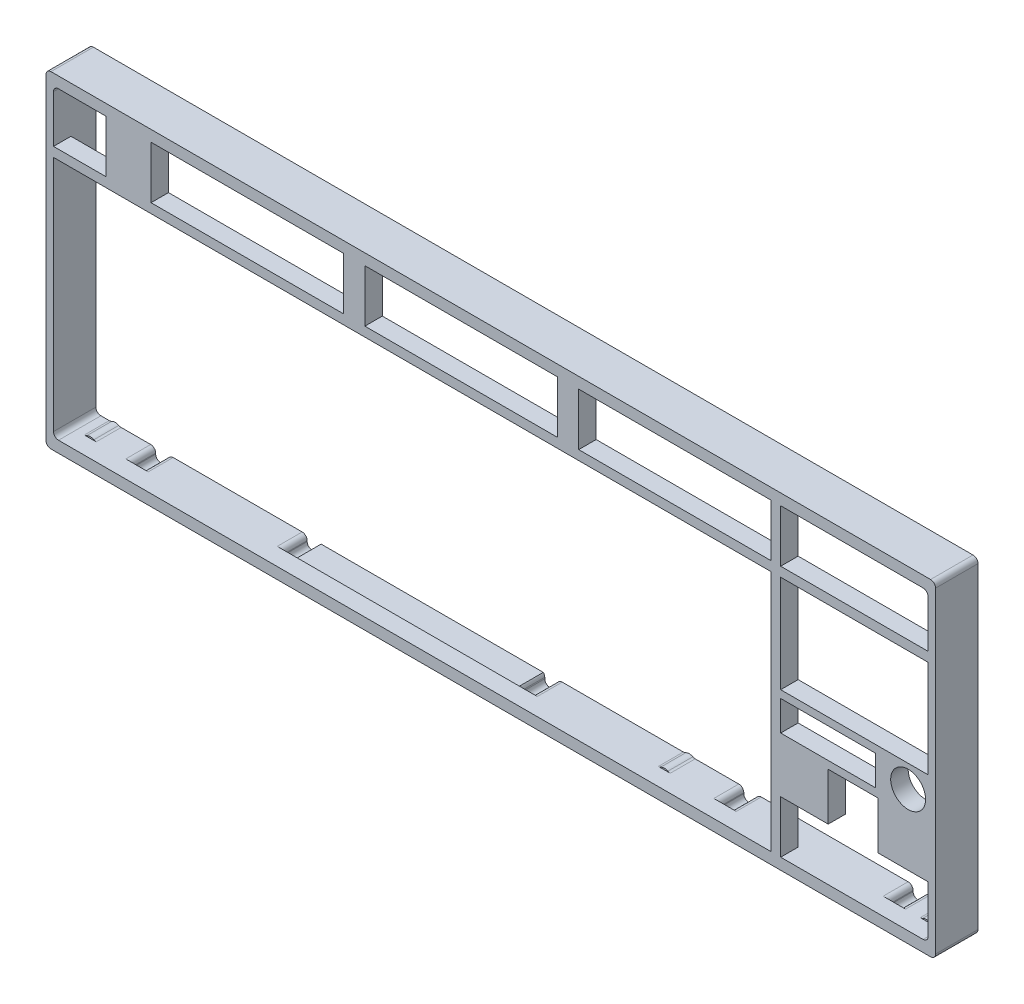
from build123d import *

# Parameters (mm, degrees)
SKETCH7_W                               = 356.6125
SKETCH7_H                               = 131.0125
BOSS_EXTRUDE3_DEPTH                     = 10
SKETCH10_W                              = 356.6125
SKETCH10_H                              = 131.0125
BOSS_EXTRUDE4_DEPTH                     = 7
BOSS_EXTRUDE5_DEPTH                     = 7
FILLET1_R                               = 2
F_1_16_0_0625_DIAMETER_HOLE1_AT_2_COUNT = 2
F_1_16_0_0625_DIAMETER_HOLE1_AT_2_PITCH = 105.000160723
F_1_16_0_0625_DIAMETER_HOLE1_AT_3_COUNT = 2
F_1_16_0_0625_DIAMETER_HOLE1_AT_3_PITCH = 230.112573338
F_1_16_0_0625_DIAMETER_HOLE1_AT_4_COUNT = 2
F_1_16_0_0625_DIAMETER_HOLE1_AT_4_PITCH = 335.112550359
SKETCH17_R                              = 7
SKETCH17_W                              = 38
SKETCH17_H                              = 12
CUT_EXTRUDE1_DEPTH                      = 10


with BuildPart() as part:
    # Sketch7 → Boss-Extrude3 (new body)
    with BuildSketch(Plane.XY):
        with Locations((178.80625, 57.933485256)):
            Rectangle(SKETCH7_W, SKETCH7_H)
        with BuildLine():
            Line((354.1125, 116.989735256), (354.1125, -1.022764744))
            ThreePointArc((354.1125, -1.022764744), (353.526713562, -2.436978306), (352.1125, -3.022764744))
            Line((352.1125, -3.022764744), (348.737368417, -3.022764744))
            ThreePointArc((348.737368417, -3.022764744), (348.247470469, -2.961836686), (347.78742105, -2.782764744))
            ThreePointArc((347.78742105, -2.782764744), (346.3625, -2.422764744), (344.93757895, -2.782764744))
            ThreePointArc((344.93757895, -2.782764744), (344.477529531, -2.961836686), (343.987631583, -3.022764744))
            Line((343.987631583, -3.022764744), (338.0875, -3.022764744))
            ThreePointArc((338.0875, -3.022764744), (336.673286438, -3.608551181), (336.0875, -5.022764744))
            Line((336.0875, -5.022764744), (336.0875, -5.372764744))
            ThreePointArc((336.0875, -5.372764744), (335.501713562, -6.786978306), (334.0875, -7.372764744))
            Line((334.0875, -7.372764744), (333.0875, -7.372764744))
            ThreePointArc((333.0875, -7.372764744), (331.673286438, -6.786978306), (331.0875, -5.372764744))
            Line((331.0875, -5.372764744), (331.0875, -5.022764744))
            ThreePointArc((331.0875, -5.022764744), (330.501713562, -3.608551181), (329.0875, -3.022764744))
            Line((329.0875, -3.022764744), (270.221875, -3.022764744))
            ThreePointArc((270.221875, -3.022764744), (268.807661438, -3.608551181), (268.221875, -5.022764744))
            Line((268.221875, -5.022764744), (268.221875, -5.372764744))
            ThreePointArc((268.221875, -5.372764744), (267.636088562, -6.786978306), (266.221875, -7.372764744))
            Line((266.221875, -7.372764744), (265.221875, -7.372764744))
            ThreePointArc((265.221875, -7.372764744), (263.807661438, -6.786978306), (263.221875, -5.372764744))
            Line((263.221875, -5.372764744), (263.221875, -5.022764744))
            ThreePointArc((263.221875, -5.022764744), (262.636088562, -3.608551181), (261.221875, -3.022764744))
            Line((261.221875, -3.022764744), (243.737368417, -3.022764744))
            ThreePointArc((243.737368417, -3.022764744), (243.247470469, -2.961836686), (242.78742105, -2.782764744))
            ThreePointArc((242.78742105, -2.782764744), (241.3625, -2.422764744), (239.93757895, -2.782764744))
            ThreePointArc((239.93757895, -2.782764744), (239.477529531, -2.961836686), (238.987631583, -3.022764744))
            Line((238.987631583, -3.022764744), (190.44375, -3.022764744))
            ThreePointArc((190.44375, -3.022764744), (189.029536438, -3.608551181), (188.44375, -5.022764744))
            Line((188.44375, -5.022764744), (188.44375, -5.372764744))
            ThreePointArc((188.44375, -5.372764744), (187.857963562, -6.786978306), (186.44375, -7.372764744))
            Line((186.44375, -7.372764744), (185.44375, -7.372764744))
            ThreePointArc((185.44375, -7.372764744), (184.029536438, -6.786978306), (183.44375, -5.372764744))
            Line((183.44375, -5.372764744), (183.44375, -4.851191868))
            ThreePointArc((183.44375, -4.851191868), (183.291509065, -4.085825004), (182.857963562, -3.436978306))
            Line((182.857963562, -3.436978306), (93.785786438, -3.436978306))
            ThreePointArc((93.785786438, -3.436978306), (93.352240935, -4.085825004), (93.2, -4.851191868))
            Line((93.2, -4.851191868), (93.2, -5.372764744))
            ThreePointArc((93.2, -5.372764744), (92.614213562, -6.786978306), (91.2, -7.372764744))
            Line((91.2, -7.372764744), (90.2, -7.372764744))
            ThreePointArc((90.2, -7.372764744), (88.785786438, -6.786978306), (88.2, -5.372764744))
            Line((88.2, -5.372764744), (88.2, -5.022764744))
            ThreePointArc((88.2, -5.022764744), (87.614213562, -3.608551181), (86.2, -3.022764744))
            Line((86.2, -3.022764744), (34.478125, -3.022764744))
            ThreePointArc((34.478125, -3.022764744), (33.063911438, -3.608551181), (32.478125, -5.022764744))
            Line((32.478125, -5.022764744), (32.478125, -5.372764744))
            ThreePointArc((32.478125, -5.372764744), (31.892338562, -6.786978306), (30.478125, -7.372764744))
            Line((30.478125, -7.372764744), (29.478125, -7.372764744))
            ThreePointArc((29.478125, -7.372764744), (28.063911438, -6.786978306), (27.478125, -5.372764744))
            Line((27.478125, -5.372764744), (27.478125, -5.022764744))
            ThreePointArc((27.478125, -5.022764744), (26.892338562, -3.608551181), (25.478125, -3.022764744))
            Line((25.478125, -3.022764744), (13.624868417, -3.022764744))
            ThreePointArc((13.624868417, -3.022764744), (13.134970469, -2.961836686), (12.67492105, -2.782764744))
            ThreePointArc((12.67492105, -2.782764744), (11.25, -2.422764744), (9.82507895, -2.782764744))
            ThreePointArc((9.82507895, -2.782764744), (9.365029531, -2.961836686), (8.875131583, -3.022764744))
            Line((8.875131583, -3.022764744), (5.5, -3.022764744))
            ThreePointArc((5.5, -3.022764744), (4.085786438, -2.436978306), (3.5, -1.022764744))
            Line((3.5, -1.022764744), (3.5, 116.989735256))
            ThreePointArc((3.5, 116.989735256), (4.085786438, 118.403948819), (5.5, 118.989735256))
            Line((5.5, 118.989735256), (8.875131583, 118.989735256))
            ThreePointArc((8.875131583, 118.989735256), (9.365029531, 118.928807199), (9.82507895, 118.749735256))
            ThreePointArc((9.82507895, 118.749735256), (11.25, 118.389735256), (12.67492105, 118.749735256))
            ThreePointArc((12.67492105, 118.749735256), (13.134970469, 118.928807199), (13.624868417, 118.989735256))
            Line((13.624868417, 118.989735256), (29.05, 118.989735256))
            ThreePointArc((29.05, 118.989735256), (30.464213562, 119.575521694), (31.05, 120.989735256))
            Line((31.05, 120.989735256), (31.05, 121.339735256))
            ThreePointArc((31.05, 121.339735256), (31.635786438, 122.753948819), (33.05, 123.339735256))
            Line((33.05, 123.339735256), (34.05, 123.339735256))
            ThreePointArc((34.05, 123.339735256), (35.464213562, 122.753948819), (36.05, 121.339735256))
            Line((36.05, 121.339735256), (36.05, 120.989735256))
            ThreePointArc((36.05, 120.989735256), (36.635786438, 119.575521694), (38.05, 118.989735256))
            Line((38.05, 118.989735256), (113.875131583, 118.989735256))
            ThreePointArc((113.875131583, 118.989735256), (114.365029531, 118.928807199), (114.82507895, 118.749735256))
            ThreePointArc((114.82507895, 118.749735256), (116.25, 118.389735256), (117.67492105, 118.749735256))
            ThreePointArc((117.67492105, 118.749735256), (118.134970469, 118.928807199), (118.624868417, 118.989735256))
            Line((118.624868417, 118.989735256), (119.5375, 118.989735256))
            ThreePointArc((119.5375, 118.989735256), (120.951713562, 119.575521694), (121.5375, 120.989735256))
            Line((121.5375, 120.989735256), (121.5375, 121.339735256))
            ThreePointArc((121.5375, 121.339735256), (122.123286438, 122.753948819), (123.5375, 123.339735256))
            Line((123.5375, 123.339735256), (124.5375, 123.339735256))
            ThreePointArc((124.5375, 123.339735256), (125.951713562, 122.753948819), (126.5375, 121.339735256))
            Line((126.5375, 121.339735256), (126.5375, 120.989735256))
            ThreePointArc((126.5375, 120.989735256), (127.123286438, 119.575521694), (128.5375, 118.989735256))
            Line((128.5375, 118.989735256), (205.2625, 118.989735256))
            ThreePointArc((205.2625, 118.989735256), (206.676713562, 119.575521694), (207.2625, 120.989735256))
            Line((207.2625, 120.989735256), (207.2625, 121.339735256))
            ThreePointArc((207.2625, 121.339735256), (207.848286438, 122.753948819), (209.2625, 123.339735256))
            Line((209.2625, 123.339735256), (210.2625, 123.339735256))
            ThreePointArc((210.2625, 123.339735256), (211.676713562, 122.753948819), (212.2625, 121.339735256))
            Line((212.2625, 121.339735256), (212.2625, 120.989735256))
            ThreePointArc((212.2625, 120.989735256), (212.848286438, 119.575521694), (214.2625, 118.989735256))
            Line((214.2625, 118.989735256), (238.987631583, 118.989735256))
            ThreePointArc((238.987631583, 118.989735256), (239.477529531, 118.928807199), (239.93757895, 118.749735256))
            ThreePointArc((239.93757895, 118.749735256), (241.3625, 118.389735256), (242.78742105, 118.749735256))
            ThreePointArc((242.78742105, 118.749735256), (243.247470469, 118.928807199), (243.737368417, 118.989735256))
            Line((243.737368417, 118.989735256), (329.0875, 118.989735256))
            ThreePointArc((329.0875, 118.989735256), (330.501713562, 119.575521694), (331.0875, 120.989735256))
            Line((331.0875, 120.989735256), (331.0875, 121.339735256))
            ThreePointArc((331.0875, 121.339735256), (331.673286438, 122.753948819), (333.0875, 123.339735256))
            Line((333.0875, 123.339735256), (334.0875, 123.339735256))
            ThreePointArc((334.0875, 123.339735256), (335.501713562, 122.753948819), (336.0875, 121.339735256))
            Line((336.0875, 121.339735256), (336.0875, 120.989735256))
            ThreePointArc((336.0875, 120.989735256), (336.673286438, 119.575521694), (338.0875, 118.989735256))
            Line((338.0875, 118.989735256), (343.987631583, 118.989735256))
            ThreePointArc((343.987631583, 118.989735256), (344.477529531, 118.928807199), (344.93757895, 118.749735256))
            ThreePointArc((344.93757895, 118.749735256), (346.3625, 118.389735256), (347.78742105, 118.749735256))
            ThreePointArc((347.78742105, 118.749735256), (348.247470469, 118.928807199), (348.737368417, 118.989735256))
            Line((348.737368417, 118.989735256), (352.1125, 118.989735256))
            ThreePointArc((352.1125, 118.989735256), (353.526713562, 118.403948819), (354.1125, 116.989735256))
        make_face(mode=Mode.SUBTRACT)
    extrude(amount=BOSS_EXTRUDE3_DEPTH)



with BuildPart() as body_2:
    # Sketch10 → Boss-Extrude4 (new body)
    with BuildSketch(Plane.XY.offset(10)):
        with Locations((178.80625, 57.933485256)):
            Rectangle(SKETCH10_W, SKETCH10_H)
        with BuildLine():
            Line((243.737368417, -3.022764744), (238.987631583, -3.022764744))
            Line((238.987631583, -3.022764744), (190.44375, -3.022764744))
            Line((190.44375, -3.022764744), (86.2, -3.022764744))
            Line((86.2, -3.022764744), (34.478125, -3.022764744))
            Line((34.478125, -3.022764744), (25.478125, -3.022764744))
            Line((25.478125, -3.022764744), (13.624868417, -3.022764744))
            Line((13.624868417, -3.022764744), (8.875131583, -3.022764744))
            Line((8.875131583, -3.022764744), (5.5, -3.022764744))
            ThreePointArc((5.5, -3.022764744), (4.085786438, -2.436978306), (3.5, -1.022764744))
            Line((3.5, -1.022764744), (3.5, 93.289403059))
            Line((3.5, 93.289403059), (3.5, 99.638168203))
            Line((3.5, 99.638168203), (3.5, 116.989735256))
            ThreePointArc((3.5, 116.989735256), (4.085786438, 118.403948819), (5.5, 118.989735256))
            Line((5.5, 118.989735256), (8.875131583, 118.989735256))
            Line((8.875131583, 118.989735256), (13.624868417, 118.989735256))
            Line((13.624868417, 118.989735256), (29.05, 118.989735256))
            Line((29.05, 118.989735256), (38.05, 118.989735256))
            Line((38.05, 118.989735256), (113.875131583, 118.989735256))
            Line((113.875131583, 118.989735256), (118.624868417, 118.989735256))
            Line((118.624868417, 118.989735256), (119.5375, 118.989735256))
            Line((119.5375, 118.989735256), (128.5375, 118.989735256))
            Line((128.5375, 118.989735256), (205.2625, 118.989735256))
            Line((205.2625, 118.989735256), (214.2625, 118.989735256))
            Line((214.2625, 118.989735256), (238.987631583, 118.989735256))
            Line((238.987631583, 118.989735256), (243.737368417, 118.989735256))
            Line((243.737368417, 118.989735256), (329.0875, 118.989735256))
            Line((329.0875, 118.989735256), (338.0875, 118.989735256))
            Line((338.0875, 118.989735256), (343.987631583, 118.989735256))
            Line((343.987631583, 118.989735256), (348.737368417, 118.989735256))
            Line((348.737368417, 118.989735256), (352.1125, 118.989735256))
            ThreePointArc((352.1125, 118.989735256), (353.526713562, 118.403948819), (354.1125, 116.989735256))
            Line((354.1125, 116.989735256), (354.1125, 99.638168203))
            Line((354.1125, 99.638168203), (354.1125, 93.289403059))
            Line((354.1125, 93.289403059), (354.1125, -1.022764744))
            ThreePointArc((354.1125, -1.022764744), (353.526713562, -2.436978306), (352.1125, -3.022764744))
            Line((352.1125, -3.022764744), (348.737368417, -3.022764744))
            Line((348.737368417, -3.022764744), (343.987631583, -3.022764744))
            Line((343.987631583, -3.022764744), (338.0875, -3.022764744))
            Line((338.0875, -3.022764744), (329.0875, -3.022764744))
            Line((329.0875, -3.022764744), (270.221875, -3.022764744))
            Line((270.221875, -3.022764744), (261.221875, -3.022764744))
            Line((261.221875, -3.022764744), (243.737368417, -3.022764744))
        make_face(mode=Mode.SUBTRACT)
    extrude(amount=BOSS_EXTRUDE4_DEPTH)


with BuildPart() as part_1:
    add(part.part)

    add(body_2.part)  # Boss-Extrude5 merges body 2
    # Sketch11 → Boss-Extrude5 (add)
    with BuildSketch(Plane.XY.offset(17)):
        Polygon((3.5, 97.989735256), (3.5, 94.177235256), (291.2, 94.177235256), (291.2, -3.022764744), (295.0125, -3.022764744), (295.0125, 17.977235256), (314.0625, 17.977235256), (314.0625, 37.027235256), (334.0625, 37.027235256), (334.0625, 17.977235256), (354.1125, 17.977235256), (354.1125, 55.127235256), (295.0125, 55.127235256), (295.0125, 94.177235256), (354.1125, 94.177235256), (354.1125, 97.989735256), (295.0125, 97.989735256), (295.0125, 118.989735256), (291.2, 118.989735256), (291.2, 97.989735256), (214.05, 97.989735256), (214.05, 118.989735256), (205.475, 118.989735256), (205.475, 97.989735256), (128.325, 97.989735256), (128.325, 118.989735256), (119.75, 118.989735256), (119.75, 97.989735256), (42.6, 97.989735256), (42.6, 118.989735256), (24.5, 118.989735256), (24.5, 97.989735256), align=None)
    extrude(amount=-BOSS_EXTRUDE5_DEPTH)

    # Fillet1
    fillet1_edges = [part_1.edges().sort_by_distance(p)[0] for p in [
        (357.1125, -7.572764744, 8.5),
        (0.5, -7.572764744, 8.5),
        (0.5, 123.439735256, 8.5),
        (357.1125, 123.439735256, 8.5),
    ]]
    fillet(fillet1_edges, radius=FILLET1_R)

    # Sketch15 → 1/16 (0.0625) Diameter Hole1 (revolve, cut)
    with BuildSketch(Plane(origin=(346.3625, 121.214735256, 0), x_dir=(0, 1, 0), z_dir=(1, 0, 0))):
        Polygon((0, 0), (0, 5.476933116), (0.79375, 5), (0.79375, 0), align=None)
    f_1_16_0_0625_diameter_hole1 = revolve(axis=Axis((346.3625, 121.214735256, -6.35), (0, 0, 1)), mode=Mode.SUBTRACT)

    # 1/16 (0.0625) Diameter Hole1 at 2: 1/16 (0.0625) Diameter Hole1 ×2
    with Locations(*[Vector(-0.999998469, -0.001749681, 0) * (i * F_1_16_0_0625_DIAMETER_HOLE1_AT_2_PITCH) for i in range(1, F_1_16_0_0625_DIAMETER_HOLE1_AT_2_COUNT)]):
        add(f_1_16_0_0625_diameter_hole1, mode=Mode.SUBTRACT)

    # 1/16 (0.0625) Diameter Hole1 at 3: 1/16 (0.0625) Diameter Hole1 ×2
    with Locations(*[Vector(-0.999999681, -0.000798378, 0) * (i * F_1_16_0_0625_DIAMETER_HOLE1_AT_3_PITCH) for i in range(1, F_1_16_0_0625_DIAMETER_HOLE1_AT_3_COUNT)]):
        add(f_1_16_0_0625_diameter_hole1, mode=Mode.SUBTRACT)

    # 1/16 (0.0625) Diameter Hole1 at 4: 1/16 (0.0625) Diameter Hole1 ×2
    with Locations(*[Vector(-0.99999985, -0.000548224, 0) * (i * F_1_16_0_0625_DIAMETER_HOLE1_AT_4_PITCH) for i in range(1, F_1_16_0_0625_DIAMETER_HOLE1_AT_4_COUNT)]):
        add(f_1_16_0_0625_diameter_hole1, mode=Mode.SUBTRACT)

    # Mirror1: 1/16 (0.0625) Diameter Hole1 across plane
    add(f_1_16_0_0625_diameter_hole1.mirror(Plane.ZX.offset(57.933485256)), mode=Mode.SUBTRACT)

    # Mirror1 copy 1 sketch → Mirror1 copy 1 (revolve, cut)
    with BuildSketch(Plane(origin=(241.3625, -5.164047976, 0), x_dir=(0, -1, 0), z_dir=(1, 0, 0))):
        Polygon((0, 0), (0, -5.476933116), (0.79375, -5), (0.79375, 0), align=None)
    revolve(axis=Axis((241.3625, -5.164047976, -6.35), (0, 0, -1)), mode=Mode.SUBTRACT)

    # Mirror1 copy 2 sketch → Mirror1 copy 2 (revolve, cut)
    with BuildSketch(Plane(origin=(116.25, -5.164047976, 0), x_dir=(0, -1, 0), z_dir=(1, 0, 0))):
        Polygon((0, 0), (0, -5.476933116), (0.79375, -5), (0.79375, 0), align=None)
    revolve(axis=Axis((116.25, -5.164047976, -6.35), (0, 0, -1)), mode=Mode.SUBTRACT)

    # Mirror1 copy 3 sketch → Mirror1 copy 3 (revolve, cut)
    with BuildSketch(Plane(origin=(11.25, -5.164047976, 0), x_dir=(0, -1, 0), z_dir=(1, 0, 0))):
        Polygon((0, 0), (0, -5.476933116), (0.79375, -5), (0.79375, 0), align=None)
    revolve(axis=Axis((11.25, -5.164047976, -6.35), (0, 0, -1)), mode=Mode.SUBTRACT)

    # Sketch17 → Cut-Extrude1 (cut)
    with BuildSketch(Plane.XY.offset(17)):
        with Locations((346.1125, 46.077235256)):
            Circle(SKETCH17_R)
        with Locations((314.01, 46.077235256)):
            Rectangle(SKETCH17_W, SKETCH17_H)
    extrude(amount=-CUT_EXTRUDE1_DEPTH, mode=Mode.SUBTRACT)


solid = part_1.part
